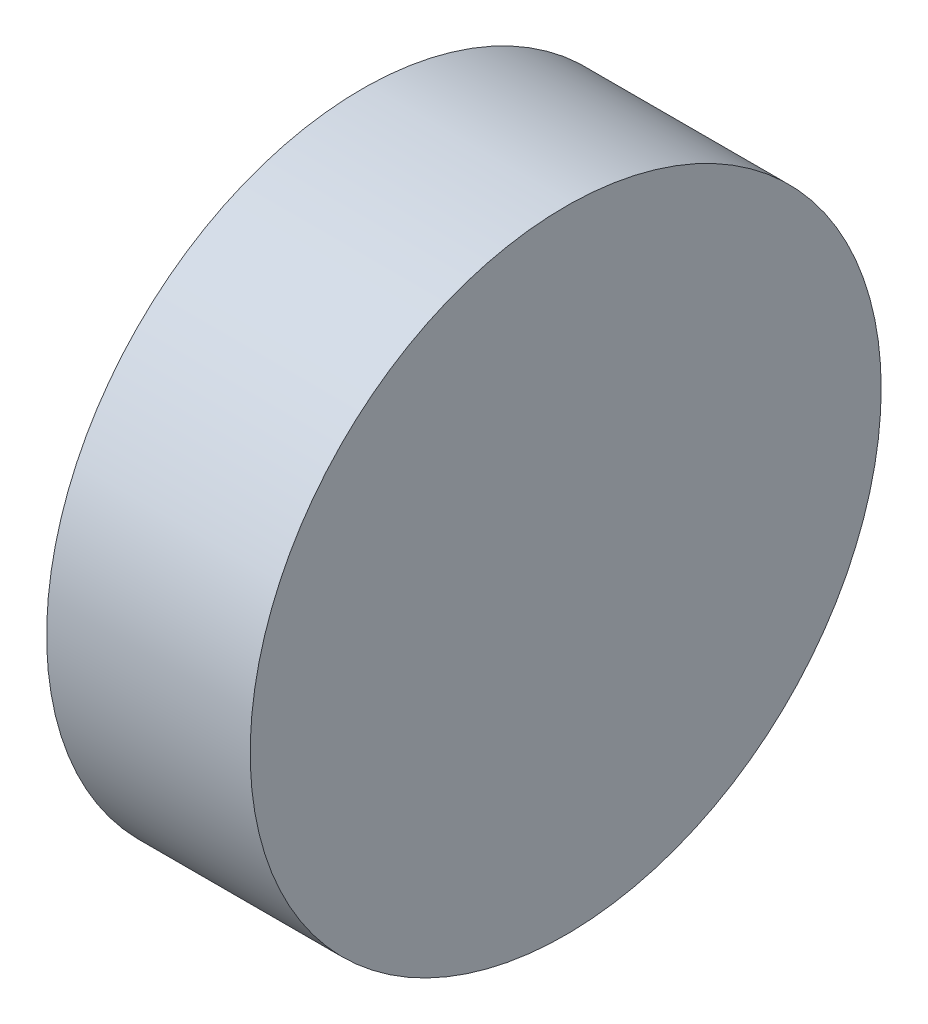
from build123d import *

# Parameters (mm, degrees)
SKETCH1_R           = 3.937
BOSS_EXTRUDE1_DEPTH = 2.54


with BuildPart() as part:
    # Sketch1 → Boss-Extrude1 (new body)
    with BuildSketch(Plane(origin=(0, 0, 0), x_dir=(0, 0, -1), z_dir=(1, 0, 0))):
        Circle(SKETCH1_R)
    extrude(amount=BOSS_EXTRUDE1_DEPTH)


solid = part.part
